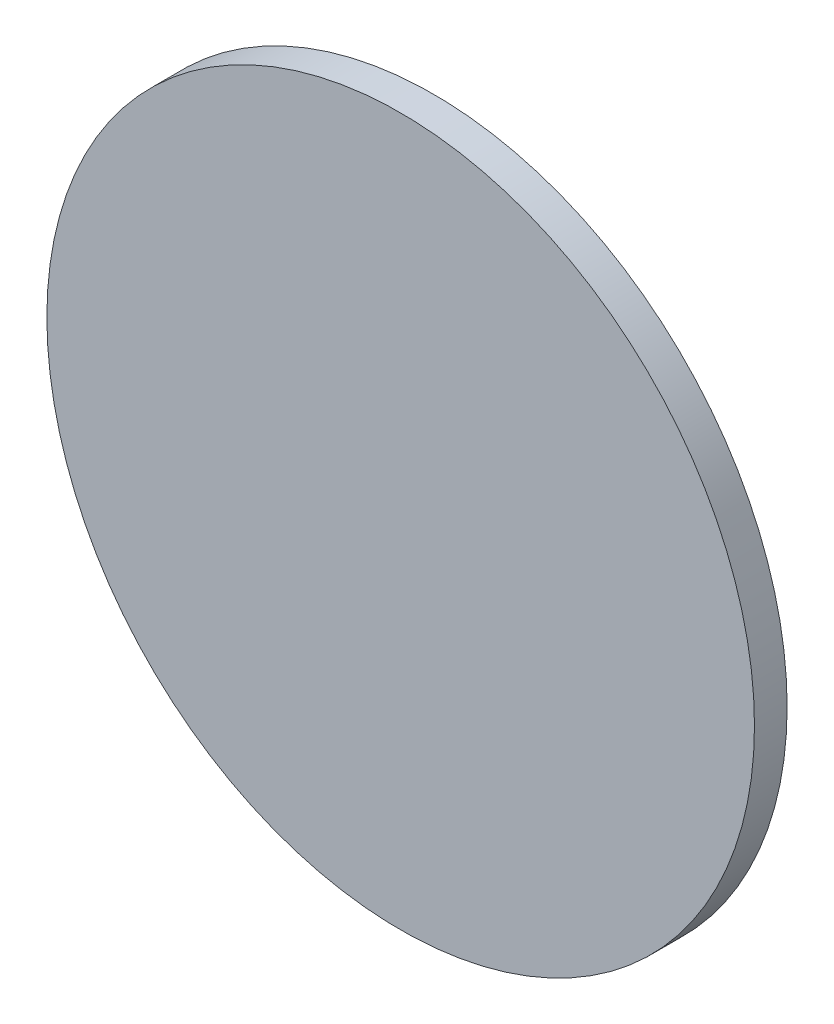
from build123d import *

# Parameters (mm, degrees)
SKETCH1_R           = 65
BOSS_EXTRUDE1_DEPTH = 6


with BuildPart() as part:
    # Sketch1 → Boss-Extrude1 (new body)
    with BuildSketch(Plane.XY):
        Circle(SKETCH1_R)
    extrude(amount=BOSS_EXTRUDE1_DEPTH)


solid = part.part
